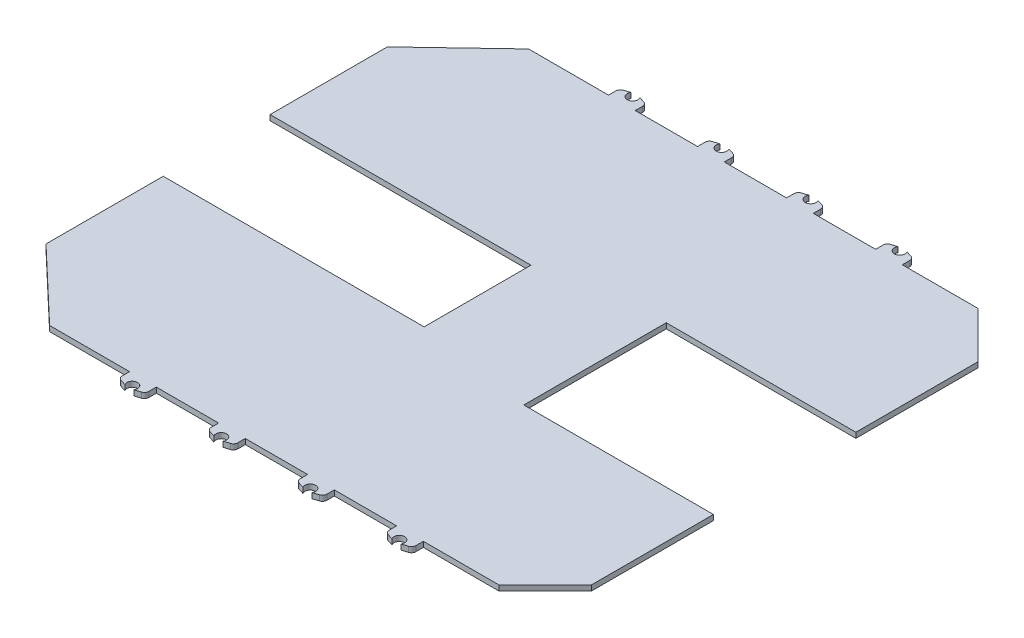
from build123d import *

# Parameters (mm, degrees)
BOSS_EXTRUDE1_DEPTH  = 6
BOSS_EXTRUDE2_DEPTH  = 6
LPATTERN1_COUNT      = 4
LPATTERN1_PITCH      = 100
MIRROR1_COPY_1_DEPTH = 6
MIRROR1_COPY_2_DEPTH = 6
MIRROR1_COPY_3_DEPTH = 6


with BuildPart() as part:
    # Sketch1 → Boss-Extrude1 (new body)
    with BuildSketch(Plane(origin=(0, 0, 0), x_dir=(1, 0, 0), z_dir=(0, 1, 0))):
        Polygon((0, 160), (213, 160), (213, 297.159379566), (161.159379566, 349), (76.159379566, 349), (46.159379566, 349), (-343.622469374, 349), (-425, 271.691345905), (-425, 140), (-132, 140), (-132, 20), (-425, 20), (-425, -111.691345905), (-343.622469374, -189), (161.159379566, -189), (213, -137.159379566), (213, 0), (0, 0), align=None)
    extrude(amount=BOSS_EXTRUDE1_DEPTH)

    # Sketch1_3 → Boss-Extrude2 (add)
    with BuildSketch(Plane(origin=(0, 0, 0), x_dir=(1, 0, 0), z_dir=(0, 1, 0))):
        with BuildLine():
            Line((46.159379566, 349), (76.159379566, 349))
            Line((76.159379566, 349), (76.159379566, 357.347672364))
            ThreePointArc((76.159379566, 357.347672364), (75.196919236, 360.296955907), (72.680070199, 362.110812085))
            Line((72.680070199, 362.110812085), (66.259379566, 364.160696126))
            ThreePointArc((66.259379566, 364.160696126), (66.929994785, 362.643167673), (67.159379566, 361))
            ThreePointArc((67.159379566, 361), (59.516211894, 355.229384781), (56.059379566, 364.160696126))
            Line((56.059379566, 364.160696126), (49.638688934, 362.110812085))
            ThreePointArc((49.638688934, 362.110812085), (47.121839897, 360.296955907), (46.159379566, 357.347672364))
            Line((46.159379566, 357.347672364), (46.159379566, 349))
        make_face()
    boss_extrude2 = extrude(amount=BOSS_EXTRUDE2_DEPTH)

    # LPattern1: Boss-Extrude2 ×4
    with Locations(*[(-i * LPATTERN1_PITCH, 0, 0) for i in range(1, LPATTERN1_COUNT)]):
        add(boss_extrude2)

    # Mirror1: Boss-Extrude2 across plane
    add(boss_extrude2.mirror(Plane.XY.offset(-80)))

    # Mirror1 copy 1 sketch → Mirror1 copy 1 (add)
    with BuildSketch(Plane(origin=(-100, 0, -160), x_dir=(1, 0, 0), z_dir=(0, 1, 0))):
        with BuildLine():
            Line((46.159379566, -349), (76.159379566, -349))
            Line((76.159379566, -349), (76.159379566, -357.347672364))
            ThreePointArc((76.159379566, -357.347672364), (75.196919236, -360.296955907), (72.680070199, -362.110812085))
            Line((72.680070199, -362.110812085), (66.259379566, -364.160696126))
            ThreePointArc((66.259379566, -364.160696126), (66.929994785, -362.643167673), (67.159379566, -361))
            ThreePointArc((67.159379566, -361), (59.516211894, -355.229384781), (56.059379566, -364.160696126))
            Line((56.059379566, -364.160696126), (49.638688934, -362.110812085))
            ThreePointArc((49.638688934, -362.110812085), (47.121839897, -360.296955907), (46.159379566, -357.347672364))
            Line((46.159379566, -357.347672364), (46.159379566, -349))
        make_face()
    extrude(amount=MIRROR1_COPY_1_DEPTH)

    # Mirror1 copy 2 sketch → Mirror1 copy 2 (add)
    with BuildSketch(Plane(origin=(-200, 0, -160), x_dir=(1, 0, 0), z_dir=(0, 1, 0))):
        with BuildLine():
            Line((46.159379566, -349), (76.159379566, -349))
            Line((76.159379566, -349), (76.159379566, -357.347672364))
            ThreePointArc((76.159379566, -357.347672364), (75.196919236, -360.296955907), (72.680070199, -362.110812085))
            Line((72.680070199, -362.110812085), (66.259379566, -364.160696126))
            ThreePointArc((66.259379566, -364.160696126), (66.929994785, -362.643167673), (67.159379566, -361))
            ThreePointArc((67.159379566, -361), (59.516211894, -355.229384781), (56.059379566, -364.160696126))
            Line((56.059379566, -364.160696126), (49.638688934, -362.110812085))
            ThreePointArc((49.638688934, -362.110812085), (47.121839897, -360.296955907), (46.159379566, -357.347672364))
            Line((46.159379566, -357.347672364), (46.159379566, -349))
        make_face()
    extrude(amount=MIRROR1_COPY_2_DEPTH)

    # Mirror1 copy 3 sketch → Mirror1 copy 3 (add)
    with BuildSketch(Plane(origin=(-300, 0, -160), x_dir=(1, 0, 0), z_dir=(0, 1, 0))):
        with BuildLine():
            Line((46.159379566, -349), (76.159379566, -349))
            Line((76.159379566, -349), (76.159379566, -357.347672364))
            ThreePointArc((76.159379566, -357.347672364), (75.196919236, -360.296955907), (72.680070199, -362.110812085))
            Line((72.680070199, -362.110812085), (66.259379566, -364.160696126))
            ThreePointArc((66.259379566, -364.160696126), (66.929994785, -362.643167673), (67.159379566, -361))
            ThreePointArc((67.159379566, -361), (59.516211894, -355.229384781), (56.059379566, -364.160696126))
            Line((56.059379566, -364.160696126), (49.638688934, -362.110812085))
            ThreePointArc((49.638688934, -362.110812085), (47.121839897, -360.296955907), (46.159379566, -357.347672364))
            Line((46.159379566, -357.347672364), (46.159379566, -349))
        make_face()
    extrude(amount=MIRROR1_COPY_3_DEPTH)


solid = part.part
